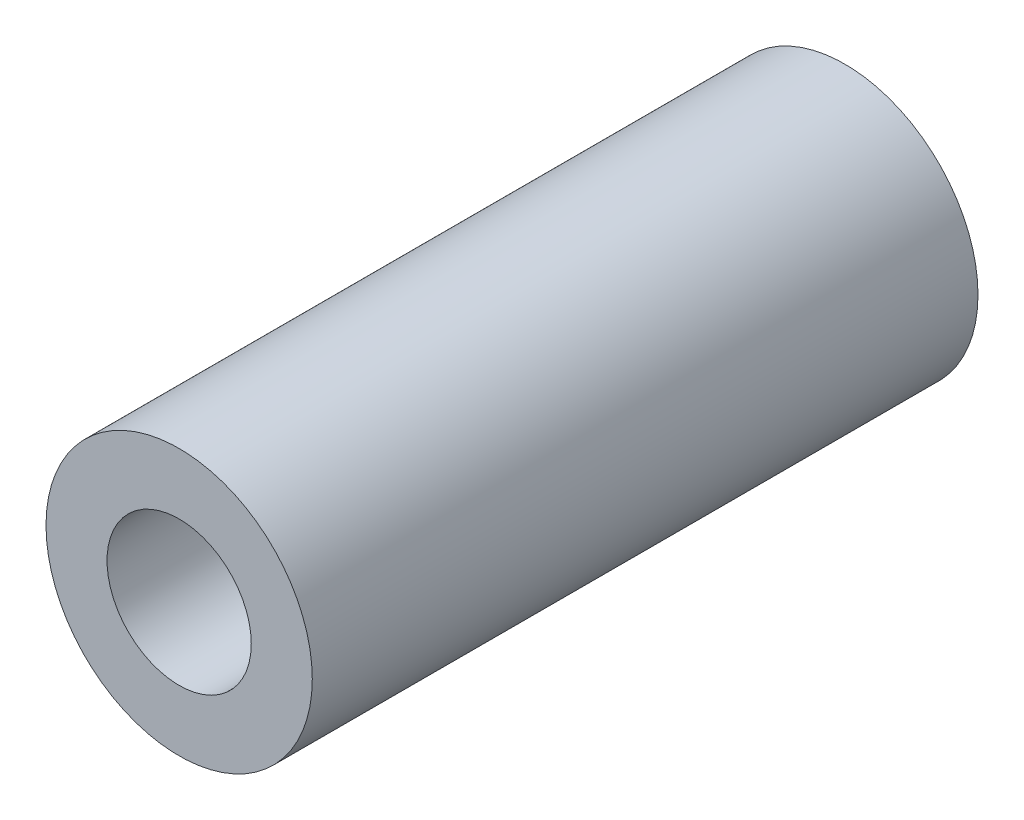
from build123d import *

# Parameters (mm, degrees)
BOSS_EXTRUDE1_DEPTH      = 25
BOSS_EXTRUDE1_DEPTH_BACK = 5
SKETCH1_R                = 6
CUT_EXTRUDE1_START       = 25
SKETCH1_4_R              = 3.25
CUT_EXTRUDE1_DEPTH       = 25


with BuildPart() as part:
    # Sketch1 → Boss-Extrude1 (new, two sides: drawn at the far end of the back side and taken through both)
    with BuildSketch(Plane.XY.offset(-BOSS_EXTRUDE1_DEPTH_BACK)):
        Circle(SKETCH1_R)
    extrude(amount=BOSS_EXTRUDE1_DEPTH + BOSS_EXTRUDE1_DEPTH_BACK)

    # Sketch1_4 → Cut-Extrude1 (cut)
    with BuildSketch(Plane.XY.offset(CUT_EXTRUDE1_START)):
        Circle(SKETCH1_4_R)
    extrude(amount=-CUT_EXTRUDE1_DEPTH, mode=Mode.SUBTRACT)


solid = part.part
